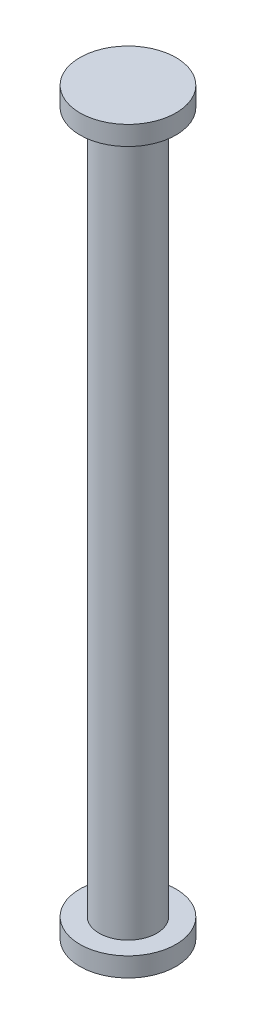
from build123d import *

# Parameters (mm, degrees)
SKETCH1_R           = 2.5
BOSS_EXTRUDE1_DEPTH = 1
SKETCH2_R           = 1.5
BOSS_EXTRUDE2_DEPTH = 36.5
SKETCH3_R           = 2.5
BOSS_EXTRUDE3_DEPTH = 1
SCALE1_SCALE        = 1.8


with BuildPart() as part:
    # Sketch1 → Boss-Extrude1 (new body)
    with BuildSketch(Plane(origin=(0, 0, 0), x_dir=(1, 0, 0), z_dir=(0, 1, 0))):
        Circle(SKETCH1_R)
    extrude(amount=BOSS_EXTRUDE1_DEPTH)

    # Sketch2 → Boss-Extrude2 (add)
    with BuildSketch(Plane(origin=(0, 1, 0), x_dir=(1, 0, 0), z_dir=(0, 1, 0))):
        Circle(SKETCH2_R)
    extrude(amount=BOSS_EXTRUDE2_DEPTH)

    # Sketch3 → Boss-Extrude3 (add)
    with BuildSketch(Plane(origin=(0, 37.5, 0), x_dir=(1, 0, 0), z_dir=(0, 1, 0))):
        Circle(SKETCH3_R)
    extrude(amount=BOSS_EXTRUDE3_DEPTH)


with BuildPart() as part_1:
    # Scale1: scaled about (0, 19.25, 0)
    add(part.part.scale(SCALE1_SCALE).moved(Location((0, -15.4, 0))))


solid = part_1.part
